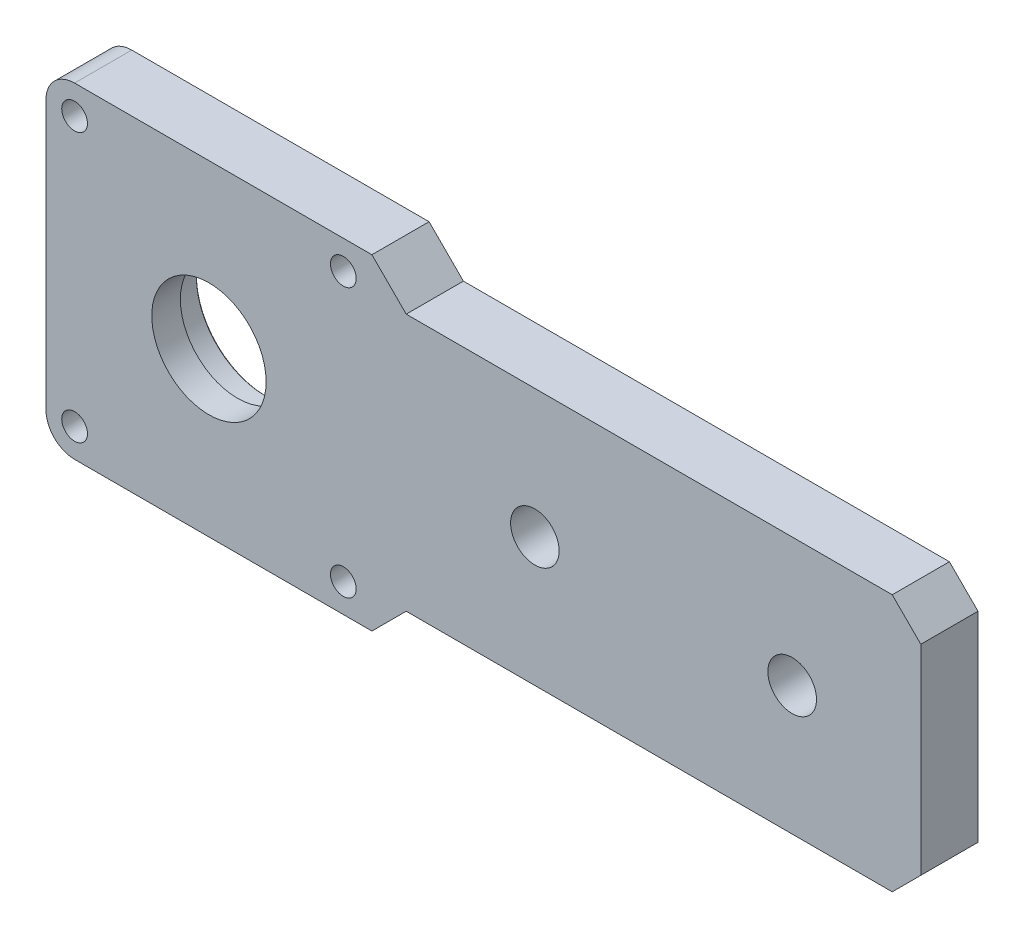
from build123d import *

# Parameters (mm, degrees)
EXTRUDE_1_DEPTH              = 5
SKETCH_6_R                   = 10
CUT_EXTRUDE_1513_DEPTH       = 10
SKETCH_19_R                  = 12
CUT_EXTRUDE_1929_DEPTH       = 5
HOLE_WIZARD_8_5_8_5_1_D      = 8.5
HOLE_WIZARD_1_D              = 4.5
HOLE_WIZARD_1_CBORE_D        = 8
HOLE_WIZARD_1_CBORE_DEPTH    = 4.6
FILLET_1_R                   = 5
CHAMFER_1_SIZE               = 5
CHAMFER_2_SIZE               = 0.2
HOLE_WIZARD_M4_1_D           = 3.3
HOLE_WIZARD_M4_1_DEPTH       = 15.5
HOLE_WIZARD_M4_1_CSINK_D     = 4.05
HOLE_WIZARD_M4_1_CSINK_ANGLE = 120


with BuildPart() as part:
    # 草图1 → 凸台-拉伸1 (new body, symmetric)
    with BuildSketch(Plane.XY):
        Polygon((28.5, 28.5), (-28.5, 28.5), (-28.5, -28.5), (28.5, -28.5), (34.5, -22.5), (124.5, -22.5), (124.5, 22.5), (34.5, 22.5), align=None)
    extrude(amount=EXTRUDE_1_DEPTH, both=True)

    # 草图6 → Cut-Extrude 1513 (cut)
    with BuildSketch(Plane.XY.offset(5)):
        Circle(SKETCH_6_R)
    extrude(amount=-CUT_EXTRUDE_1513_DEPTH, mode=Mode.SUBTRACT)

    # 草图19 → Cut-Extrude 1929 (cut)
    with BuildSketch(Plane(origin=(0, 0, -5), x_dir=(-1, 0, 0), z_dir=(0, 0, -1))):
        Circle(SKETCH_19_R)
    extrude(amount=-CUT_EXTRUDE_1929_DEPTH, mode=Mode.SUBTRACT)

    # Ø8.5 (8.5) 直径孔1 (through all)
    with Locations(Plane.XY.offset(5)):
        with Locations((57, 0), (102, 0)):
            Hole(HOLE_WIZARD_8_5_8_5_1_D / 2)

    # 打孔尺寸(%根据)内六角圆柱头螺钉的类型1 (through all)
    with Locations(Plane(origin=(0, 0, -5), x_dir=(-1, 0, 0), z_dir=(0, 0, -1))):
        with Locations((-23.5, 23.5), (23.5, 23.5), (23.5, -23.5), (-23.5, -23.5)):
            CounterBoreHole(HOLE_WIZARD_1_D / 2, HOLE_WIZARD_1_CBORE_D / 2, HOLE_WIZARD_1_CBORE_DEPTH)

    # 圆角1
    fillet_1_edges = [part.edges().sort_by_distance(p)[0] for p in [
        (-28.5, -28.5, 0),
        (-28.5, 28.5, 0),
    ]]
    fillet(fillet_1_edges, radius=FILLET_1_R)

    # 倒角1
    chamfer_1_edges = [part.edges().sort_by_distance(p)[0] for p in [
        (124.5, 22.5, 0),
        (124.5, -22.5, 0),
    ]]
    chamfer(chamfer_1_edges, length=CHAMFER_1_SIZE)

    # 倒角2
    chamfer_2_edges = [part.edges().sort_by_distance(p)[0] for p in [
        (12, 0, -5),
    ]]
    chamfer(chamfer_2_edges, length=CHAMFER_2_SIZE)

    # M4 螺纹孔1
    with Locations(Plane.ZY.offset(28.5)):
        with Locations((0, 12.5), (0, -12.5)):
            CounterSinkHole(HOLE_WIZARD_M4_1_D / 2, HOLE_WIZARD_M4_1_CSINK_D / 2, depth=HOLE_WIZARD_M4_1_DEPTH, counter_sink_angle=HOLE_WIZARD_M4_1_CSINK_ANGLE)


solid = part.part
